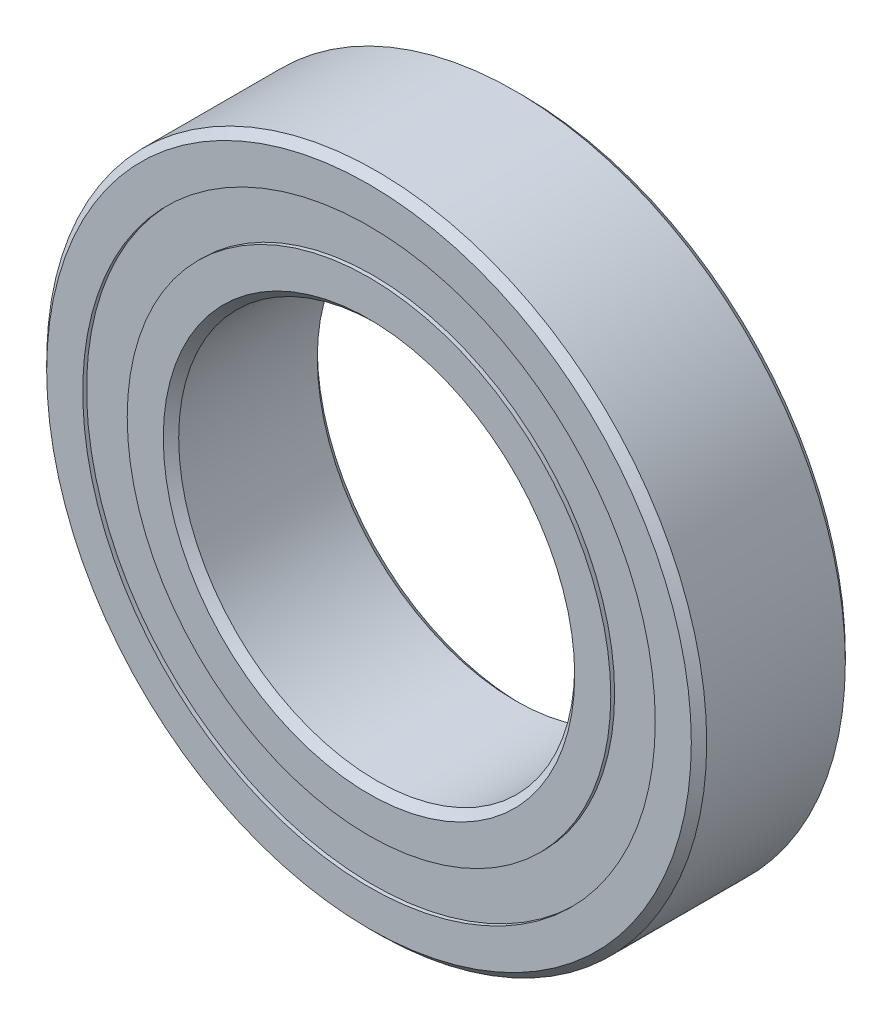
from build123d import *

# Parameters (mm, degrees)
CIRPATTERN1_COUNT = 12
SKETCH5_W         = 1.469777138
SKETCH5_H         = 2.021978022


with BuildPart() as part:
    # Sketch1 → Revolve1 (revolve)
    with BuildSketch(Plane(origin=(0, 0, 0), x_dir=(0, 0, -1), z_dir=(1, 0, 0))):
        with BuildLine():
            Line((3.15, 15), (-3.15, 15))
            Line((-3.15, 15), (-3.5, 14.65))
            Line((-3.5, 14.65), (-3.5, 13.010989011))
            Line((-3.5, 13.010989011), (-1.555555556, 13.010989011))
            ThreePointArc((-1.555555556, 13.010989011), (0, 13.855222862), (1.555555556, 13.010989011))
            Line((1.555555556, 13.010989011), (3.5, 13.010989011))
            Line((3.5, 13.010989011), (3.5, 14.65))
            Line((3.5, 14.65), (3.15, 15))
        make_face()
    revolve(axis=Axis((0, 0, 3.5), (0, 0, -1)))


with BuildPart() as body_2:
    # Sketch3 → Revolve3 (revolve)
    with BuildSketch(Plane(origin=(0, 0, 0), x_dir=(0, 0, -1), z_dir=(1, 0, 0))):
        with BuildLine():
            Line((-3.5, 10.989010989), (-1.555555556, 10.989010989))
            ThreePointArc((-1.555555556, 10.989010989), (0, 10.144777138), (1.555555556, 10.989010989))
            Line((1.555555556, 10.989010989), (3.5, 10.989010989))
            Line((3.5, 10.989010989), (3.5, 9.35))
            Line((3.5, 9.35), (3.15, 9))
            Line((3.15, 9), (-3.15, 9))
            Line((-3.15, 9), (-3.5, 9.35))
            Line((-3.5, 9.35), (-3.5, 10.989010989))
        make_face()
    revolve(axis=Axis((0, 0, 3.5), (0, 0, -1)))


with BuildPart() as body_3:
    # Sketch4 → Revolve4 (revolve)
    with BuildSketch(Plane(origin=(0, 0, 0), x_dir=(0, 0, -1), z_dir=(1, 0, 0))):
        with BuildLine():
            Line((-1.855222862, 12), (1.855222862, 12))
            ThreePointArc((1.855222862, 12), (0, 13.855222862), (-1.855222862, 12))
        make_face()
    revolve(axis=Axis((0, 12, 1.855222862), (0, 0, -1)))


with BuildPart() as cirpattern1_1:
    # CirPattern1: pattern copy
    add(body_3.part.rotate(Axis((0, 0, -3.5), (0, 0, 1)), 1 * 360 / CIRPATTERN1_COUNT))


with BuildPart() as cirpattern1_2:
    # CirPattern1: pattern copy
    add(body_3.part.rotate(Axis((0, 0, -3.5), (0, 0, 1)), 2 * 360 / CIRPATTERN1_COUNT))


with BuildPart() as cirpattern1_3:
    # CirPattern1: pattern copy
    add(body_3.part.rotate(Axis((0, 0, -3.5), (0, 0, 1)), 3 * 360 / CIRPATTERN1_COUNT))


with BuildPart() as cirpattern1_4:
    # CirPattern1: pattern copy
    add(body_3.part.rotate(Axis((0, 0, -3.5), (0, 0, 1)), 4 * 360 / CIRPATTERN1_COUNT))


with BuildPart() as cirpattern1_5:
    # CirPattern1: pattern copy
    add(body_3.part.rotate(Axis((0, 0, -3.5), (0, 0, 1)), 5 * 360 / CIRPATTERN1_COUNT))


with BuildPart() as cirpattern1_6:
    # CirPattern1: pattern copy
    add(body_3.part.rotate(Axis((0, 0, -3.5), (0, 0, 1)), 6 * 360 / CIRPATTERN1_COUNT))


with BuildPart() as cirpattern1_7:
    # CirPattern1: pattern copy
    add(body_3.part.rotate(Axis((0, 0, -3.5), (0, 0, 1)), 7 * 360 / CIRPATTERN1_COUNT))


with BuildPart() as cirpattern1_8:
    # CirPattern1: pattern copy
    add(body_3.part.rotate(Axis((0, 0, -3.5), (0, 0, 1)), 8 * 360 / CIRPATTERN1_COUNT))


with BuildPart() as cirpattern1_9:
    # CirPattern1: pattern copy
    add(body_3.part.rotate(Axis((0, 0, -3.5), (0, 0, 1)), 9 * 360 / CIRPATTERN1_COUNT))


with BuildPart() as cirpattern1_10:
    # CirPattern1: pattern copy
    add(body_3.part.rotate(Axis((0, 0, -3.5), (0, 0, 1)), 10 * 360 / CIRPATTERN1_COUNT))


with BuildPart() as cirpattern1_11:
    # CirPattern1: pattern copy
    add(body_3.part.rotate(Axis((0, 0, -3.5), (0, 0, 1)), 11 * 360 / CIRPATTERN1_COUNT))


with BuildPart() as body_15:
    # Sketch5 → Revolve5 (revolve)
    with BuildSketch(Plane(origin=(0, 0, 0), x_dir=(0, 0, -1), z_dir=(1, 0, 0))):
        with Locations((-2.590111431, 12)):
            Rectangle(SKETCH5_W, SKETCH5_H)
        with Locations((2.590111431, 12)):
            Rectangle(SKETCH5_W, SKETCH5_H)
    revolve(axis=Axis((0, 0, 3.5), (0, 0, -1)))


solid = Compound([part.part, body_2.part, body_3.part, cirpattern1_1.part, cirpattern1_2.part, cirpattern1_3.part, cirpattern1_4.part, cirpattern1_5.part, cirpattern1_6.part, cirpattern1_7.part, cirpattern1_8.part, cirpattern1_9.part, cirpattern1_10.part, cirpattern1_11.part, body_15.part])
